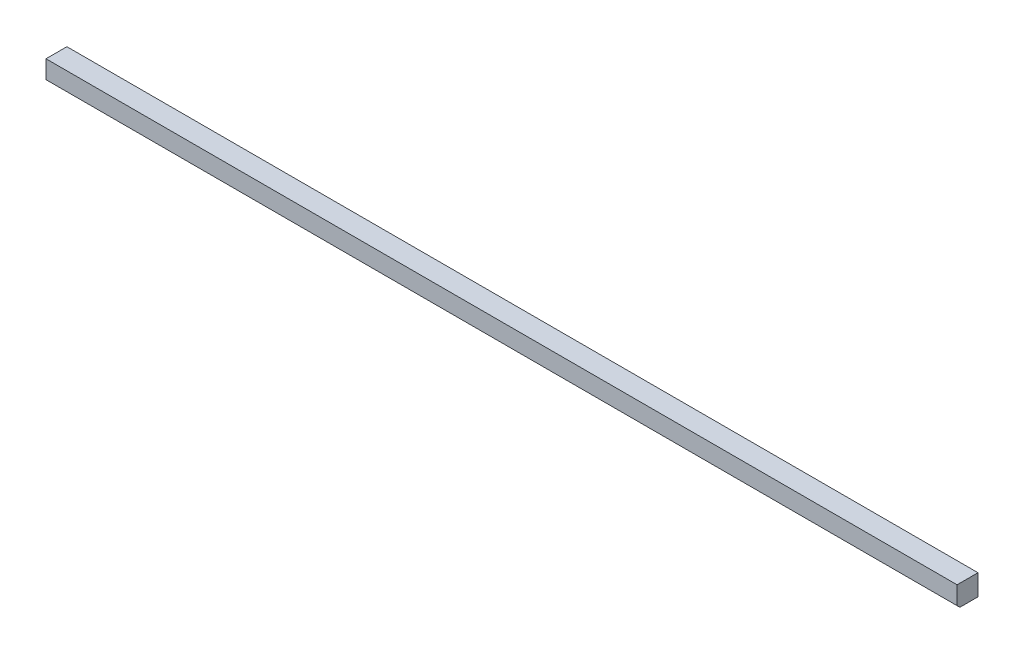
from build123d import *

# Parameters (mm, degrees)
SKETCH1_W           = 830.2752
SKETCH1_H           = 19.05
BOSS_EXTRUDE1_DEPTH = 19.05
CHAMFER1_SIZE       = 2.54


with BuildPart() as part:
    # Sketch1 → Boss-Extrude1 (new body)
    with BuildSketch(Plane(origin=(0, 0, 0), x_dir=(1, 0, 0), z_dir=(0, 1, 0))):
        with Locations((415.1376, 9.525)):
            Rectangle(SKETCH1_W, SKETCH1_H)
    extrude(amount=BOSS_EXTRUDE1_DEPTH)

    # Chamfer1
    chamfer1_edges = [part.edges().sort_by_distance(p)[0] for p in [
        (415.1376, 0, 0),
    ]]
    chamfer(chamfer1_edges, length=CHAMFER1_SIZE)


solid = part.part
